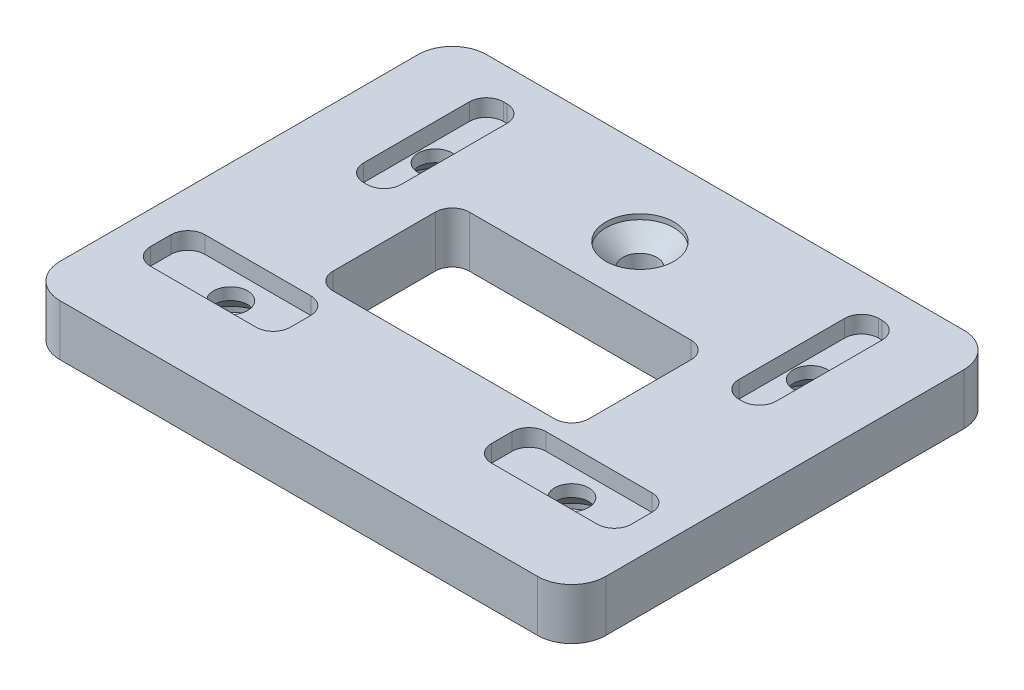
from build123d import *

# Parameters (mm, degrees)
SKETCH1_W                                      = 32
SKETCH1_H                                      = 25
BOSS_EXTRUDE1_DEPTH                            = 3
CUT_EXTRUDE1_DEPTH                             = 1
CUT_EXTRUDE2_REACH                             = 4
SKETCH3_R                                      = 1
CUT_EXTRUDE3_REACH                             = 5
SKETCH4_R                                      = 1
FILLET1_R                                      = 2
CUT_EXTRUDE4_REACH                             = 5
CSK_FOR_M2_FLAT_HEAD_MACHINE_SCREW5_AT_2_COUNT = 2
CSK_FOR_M2_FLAT_HEAD_MACHINE_SCREW5_AT_2_PITCH = 22
CSK_FOR_M2_FLAT_HEAD_MACHINE_SCREW5_AT_3_COUNT = 2
CSK_FOR_M2_FLAT_HEAD_MACHINE_SCREW5_AT_3_PITCH = 13.03840481
CSK_FOR_M2_FLAT_HEAD_MACHINE_SCREW5_AT_4_COUNT = 2
CSK_FOR_M2_FLAT_HEAD_MACHINE_SCREW5_AT_4_PITCH = 24.69817807


with BuildPart() as part:
    # Sketch1 → Boss-Extrude1 (new body)
    with BuildSketch(Plane(origin=(0, 0, 0), x_dir=(1, 0, 0), z_dir=(0, 1, 0))):
        Rectangle(SKETCH1_W, SKETCH1_H)
    extrude(amount=BOSS_EXTRUDE1_DEPTH)

    # Sketch2 → Cut-Extrude1 (cut)
    with BuildSketch(Plane(origin=(0, 3, 0), x_dir=(1, 0, 0), z_dir=(0, 1, 0))):
        with BuildLine():
            Line((14.1, -5.9), (14.1, -7.1))
            ThreePointArc((14.1, -7.1), (13.807106781, -7.807106781), (13.1, -8.1))
            Line((13.1, -8.1), (6.9, -8.1))
            ThreePointArc((6.9, -8.1), (6.192893219, -7.807106781), (5.9, -7.1))
            Line((5.9, -7.1), (5.9, -5.9))
            ThreePointArc((5.9, -5.9), (6.192893219, -5.192893219), (6.9, -4.9))
            Line((6.9, -4.9), (13.1, -4.9))
            ThreePointArc((13.1, -4.9), (13.807106781, -5.192893219), (14.1, -5.9))
        make_face()
        with BuildLine():
            Line((-13.1, -4.9), (-6.9, -4.9))
            ThreePointArc((-6.9, -4.9), (-6.192893219, -5.192893219), (-5.9, -5.9))
            Line((-5.9, -5.9), (-5.9, -7.1))
            ThreePointArc((-5.9, -7.1), (-6.192893219, -7.807106781), (-6.9, -8.1))
            Line((-6.9, -8.1), (-13.1, -8.1))
            ThreePointArc((-13.1, -8.1), (-13.807106781, -7.807106781), (-14.1, -7.1))
            Line((-14.1, -7.1), (-14.1, -5.9))
            ThreePointArc((-14.1, -5.9), (-13.807106781, -5.192893219), (-13.1, -4.9))
        make_face()
        with BuildLine():
            Line((11.1, 10.6), (10.9, 10.6))
            ThreePointArc((10.9, 10.6), (10.192893219, 10.307106781), (9.9, 9.6))
            Line((9.9, 9.6), (9.9, 3.4))
            ThreePointArc((9.9, 3.4), (10.192893219, 2.692893219), (10.9, 2.4))
            Line((10.9, 2.4), (11.1, 2.4))
            ThreePointArc((11.1, 2.4), (11.807106781, 2.692893219), (12.1, 3.4))
            Line((12.1, 3.4), (12.1, 9.6))
            ThreePointArc((12.1, 9.6), (11.807106781, 10.307106781), (11.1, 10.6))
        make_face()
        with BuildLine():
            Line((-11.1, 10.6), (-10.9, 10.6))
            ThreePointArc((-10.9, 10.6), (-10.192893219, 10.307106781), (-9.9, 9.6))
            Line((-9.9, 9.6), (-9.9, 3.4))
            ThreePointArc((-9.9, 3.4), (-10.192893219, 2.692893219), (-10.9, 2.4))
            Line((-10.9, 2.4), (-11.1, 2.4))
            ThreePointArc((-11.1, 2.4), (-11.807106781, 2.692893219), (-12.1, 3.4))
            Line((-12.1, 3.4), (-12.1, 9.6))
            ThreePointArc((-12.1, 9.6), (-11.807106781, 10.307106781), (-11.1, 10.6))
        make_face()
    extrude(amount=-CUT_EXTRUDE1_DEPTH, mode=Mode.SUBTRACT)

    # Sketch3 → Cut-Extrude2 (cut, up to next)
    with BuildSketch(Plane(origin=(0, 2, 0), x_dir=(1, 0, 0), z_dir=(0, 1, 0)), mode=Mode.PRIVATE) as cut_extrude2_sk1:
        with Locations((-10, -6.5)):
            Circle(SKETCH3_R)
    cut_extrude2_tool1 = extrude(cut_extrude2_sk1.sketch, amount=-CUT_EXTRUDE2_REACH, mode=Mode.PRIVATE) & part.part
    add(cut_extrude2_tool1.solids().sort_by_distance((-10, 2, 6.5))[0], mode=Mode.SUBTRACT)
    # Sketch3 → Cut-Extrude2 (cut, up to next)
    with BuildSketch(Plane(origin=(0, 2, 0), x_dir=(1, 0, 0), z_dir=(0, 1, 0)), mode=Mode.PRIVATE) as cut_extrude2_sk2:
        with Locations((10, -6.5)):
            Circle(SKETCH3_R)
    cut_extrude2_tool2 = extrude(cut_extrude2_sk2.sketch, amount=-CUT_EXTRUDE2_REACH, mode=Mode.PRIVATE) & part.part
    add(cut_extrude2_tool2.solids().sort_by_distance((10, 2, 6.5))[0], mode=Mode.SUBTRACT)
    # Sketch3 → Cut-Extrude2 (cut, up to next)
    with BuildSketch(Plane(origin=(0, 2, 0), x_dir=(1, 0, 0), z_dir=(0, 1, 0)), mode=Mode.PRIVATE) as cut_extrude2_sk3:
        with Locations((-11, 6.5)):
            Circle(SKETCH3_R)
    cut_extrude2_tool3 = extrude(cut_extrude2_sk3.sketch, amount=-CUT_EXTRUDE2_REACH, mode=Mode.PRIVATE) & part.part
    add(cut_extrude2_tool3.solids().sort_by_distance((-11, 2, -6.5))[0], mode=Mode.SUBTRACT)
    # Sketch3 → Cut-Extrude2 (cut, up to next)
    with BuildSketch(Plane(origin=(0, 2, 0), x_dir=(1, 0, 0), z_dir=(0, 1, 0)), mode=Mode.PRIVATE) as cut_extrude2_sk4:
        with Locations((11, 6.5)):
            Circle(SKETCH3_R)
    cut_extrude2_tool4 = extrude(cut_extrude2_sk4.sketch, amount=-CUT_EXTRUDE2_REACH, mode=Mode.PRIVATE) & part.part
    add(cut_extrude2_tool4.solids().sort_by_distance((11, 2, -6.5))[0], mode=Mode.SUBTRACT)

    # Sketch4 → Cut-Extrude3 (cut, up to next)
    with BuildSketch(Plane(origin=(0, 3, 0), x_dir=(1, 0, 0), z_dir=(0, 1, 0)), mode=Mode.PRIVATE) as cut_extrude3_sk1:
        with Locations((0, 7.5)):
            Circle(SKETCH4_R)
    cut_extrude3_tool1 = extrude(cut_extrude3_sk1.sketch, amount=-CUT_EXTRUDE3_REACH, mode=Mode.PRIVATE) & part.part
    add(cut_extrude3_tool1.solids().sort_by_distance((0, 3, -7.5))[0], mode=Mode.SUBTRACT)

    # Sketch12 → CSK for M2 Flat Head Machine Screw4 (revolve, cut)
    with BuildSketch(Plane(origin=(0, 3, -7.5), x_dir=(0, 0, 1), z_dir=(1, 0, 0))):
        Polygon((0, 0), (0, 3), (1, 3), (1, 1.3), (2, 0.3), (2, 0), align=None)
    revolve(axis=Axis((0, 9.35, -7.5), (0, -1, 0)), mode=Mode.SUBTRACT)

    # Fillet1
    fillet1_edges = [part.edges().sort_by_distance(p)[0] for p in [
        (-16, 1.5, -12.5),
        (16, 1.5, -12.5),
        (16, 1.5, 12.5),
        (-16, 1.5, 12.5),
    ]]
    fillet(fillet1_edges, radius=FILLET1_R)

    # Sketch13 → Cut-Extrude4 (cut, up to next)
    with BuildSketch(Plane(origin=(0, 3, 0), x_dir=(1, 0, 0), z_dir=(0, 1, 0)), mode=Mode.PRIVATE) as cut_extrude4_sk1:
        with BuildLine():
            Line((6.5, 4), (-6.5, 4))
            ThreePointArc((-6.5, 4), (-7.207106781, 3.707106781), (-7.5, 3))
            Line((-7.5, 3), (-7.5, -3))
            ThreePointArc((-7.5, -3), (-7.207106781, -3.707106781), (-6.5, -4))
            Line((-6.5, -4), (6.5, -4))
            ThreePointArc((6.5, -4), (7.207106781, -3.707106781), (7.5, -3))
            Line((7.5, -3), (7.5, 3))
            ThreePointArc((7.5, 3), (7.207106781, 3.707106781), (6.5, 4))
        make_face()
    cut_extrude4_tool1 = extrude(cut_extrude4_sk1.sketch, amount=-CUT_EXTRUDE4_REACH, mode=Mode.PRIVATE) & part.part
    add(cut_extrude4_tool1.solids().sort_by_distance((0, 3, 0))[0], mode=Mode.SUBTRACT)

    # Sketch15 → CSK for M2 Flat Head Machine Screw5 (revolve, cut)
    with BuildSketch(Plane(origin=(11, 0, -6.5), x_dir=(0, 0, -1), z_dir=(1, 0, 0))):
        Polygon((0, 0), (0, 3), (1, 3), (1, 1.3), (2, 0.3), (2, 0), align=None)
    csk_for_m2_flat_head_machine_screw5 = revolve(axis=Axis((11, -6.35, -6.5), (0, 1, 0)), mode=Mode.SUBTRACT)

    # CSK for M2 Flat Head Machine Screw5 at 2: CSK for M2 Flat Head Machine Screw5 ×2
    with Locations(*[(-i * CSK_FOR_M2_FLAT_HEAD_MACHINE_SCREW5_AT_2_PITCH, 0, 0) for i in range(1, CSK_FOR_M2_FLAT_HEAD_MACHINE_SCREW5_AT_2_COUNT)]):
        add(csk_for_m2_flat_head_machine_screw5, mode=Mode.SUBTRACT)

    # CSK for M2 Flat Head Machine Screw5 at 3: CSK for M2 Flat Head Machine Screw5 ×2
    with Locations(*[Vector(-0.076696499, 0, 0.997054486) * (i * CSK_FOR_M2_FLAT_HEAD_MACHINE_SCREW5_AT_3_PITCH) for i in range(1, CSK_FOR_M2_FLAT_HEAD_MACHINE_SCREW5_AT_3_COUNT)]):
        add(csk_for_m2_flat_head_machine_screw5, mode=Mode.SUBTRACT)

    # CSK for M2 Flat Head Machine Screw5 at 4: CSK for M2 Flat Head Machine Screw5 ×2
    with Locations(*[Vector(-0.850265147, 0, 0.526354615) * (i * CSK_FOR_M2_FLAT_HEAD_MACHINE_SCREW5_AT_4_PITCH) for i in range(1, CSK_FOR_M2_FLAT_HEAD_MACHINE_SCREW5_AT_4_COUNT)]):
        add(csk_for_m2_flat_head_machine_screw5, mode=Mode.SUBTRACT)


solid = part.part
